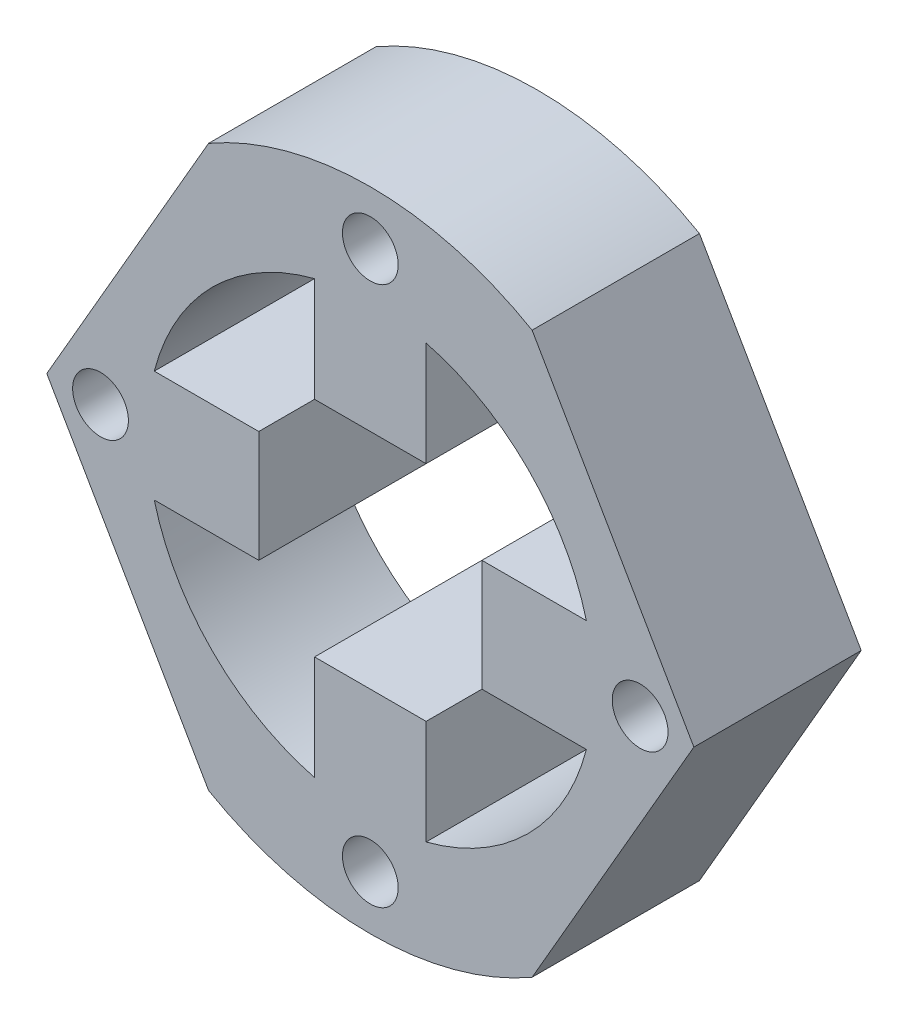
from build123d import *

# Parameters (mm, degrees)
SKETCH6_R                 = 29
SKETCH6_R_2               = 20
INNER_RING_DEPTH          = 15
MOTOR_CONNECTOR_CUT_DEPTH = 15
SKETCH8_R                 = 2.5
M3_HOLES_DEPTH            = 38
M3_HOLES_DEPTH_BACK       = 53
CUT_EXTRUDE1_DEPTH        = 16
CUT_EXTRUDE1_DEPTH_BACK   = 27


with BuildPart() as part:
    # Sketch6 → Inner Ring (new body)
    with BuildSketch(Plane.XY):
        Circle(SKETCH6_R)
        Circle(SKETCH6_R_2, mode=Mode.SUBTRACT)
    extrude(amount=-INNER_RING_DEPTH)

    # Sketch7 → Motor Connector Cut (add)
    with BuildSketch(Plane.XY):
        with BuildLine():
            ThreePointArc((20, 0), (19.840593925, 2.52008585), (19.364916731, 5))
            Line((19.364916731, 5), (9.999996731, 5))
            Line((9.999996731, 5), (9.999996731, -5))
            Line((9.999996731, -5), (19.364916731, -5))
            ThreePointArc((19.364916731, -5), (19.840593925, -2.52008585), (20, 0))
        make_face()
        with BuildLine():
            ThreePointArc((5, 19.364916731), (0, 20), (-5, 19.364916731))
            Line((-5, 19.364916731), (-5, 9.999996731))
            Line((-5, 9.999996731), (5, 9.999996731))
            Line((5, 9.999996731), (5, 19.364916731))
        make_face()
        with BuildLine():
            Line((-9.999996731, -5), (-9.999996731, 5))
            Line((-9.999996731, 5), (-19.364916731, 5))
            ThreePointArc((-19.364916731, 5), (-20, 0), (-19.364916731, -5))
            Line((-19.364916731, -5), (-9.999996731, -5))
        make_face()
        with BuildLine():
            Line((-5, -9.999996731), (-5, -19.364916731))
            ThreePointArc((-5, -19.364916731), (0, -20), (5, -19.364916731))
            Line((5, -19.364916731), (5, -9.999996731))
            Line((5, -9.999996731), (-5, -9.999996731))
        make_face()
    extrude(amount=-MOTOR_CONNECTOR_CUT_DEPTH)

    # Sketch8 → M3 Holes (cut, two sides)
    with BuildSketch(Plane.XY) as m3_holes_sk:
        with Locations((0, 24.182458366)):
            Circle(SKETCH8_R)
        with Locations((24.182458366, 0)):
            Circle(SKETCH8_R)
        with Locations((0, -24.182458366)):
            Circle(SKETCH8_R)
        with Locations((-24.182458366, 0)):
            Circle(SKETCH8_R)
    extrude(amount=M3_HOLES_DEPTH, mode=Mode.SUBTRACT)
    extrude(m3_holes_sk.sketch, amount=-M3_HOLES_DEPTH_BACK, mode=Mode.SUBTRACT)

    # Sketch9 → Cut-Extrude1 (cut, two sides)
    with BuildSketch(Plane(origin=(0, 0, -15), x_dir=(-1, 0, 0), z_dir=(0, 0, -1))) as cut_extrude1_sk:
        with BuildLine():
            Line((14.5, 25.11473671), (29, 0))
            ThreePointArc((29, 0), (25.11473671, 14.5), (14.5, 25.11473671))
        make_face()
        with BuildLine():
            Line((-29, 0), (-14.5, 25.11473671))
            ThreePointArc((-14.5, 25.11473671), (-25.11473671, 14.5), (-29, 0))
        make_face()
        with BuildLine():
            ThreePointArc((-29, 0), (-25.11473671, -14.5), (-14.5, -25.11473671))
            Line((-14.5, -25.11473671), (-29, 0))
        make_face()
        with BuildLine():
            ThreePointArc((14.5, -25.11473671), (25.11473671, -14.5), (29, 0))
            Line((29, 0), (14.5, -25.11473671))
        make_face()
    extrude(amount=CUT_EXTRUDE1_DEPTH, mode=Mode.SUBTRACT)
    extrude(cut_extrude1_sk.sketch, amount=-CUT_EXTRUDE1_DEPTH_BACK, mode=Mode.SUBTRACT)


solid = part.part
